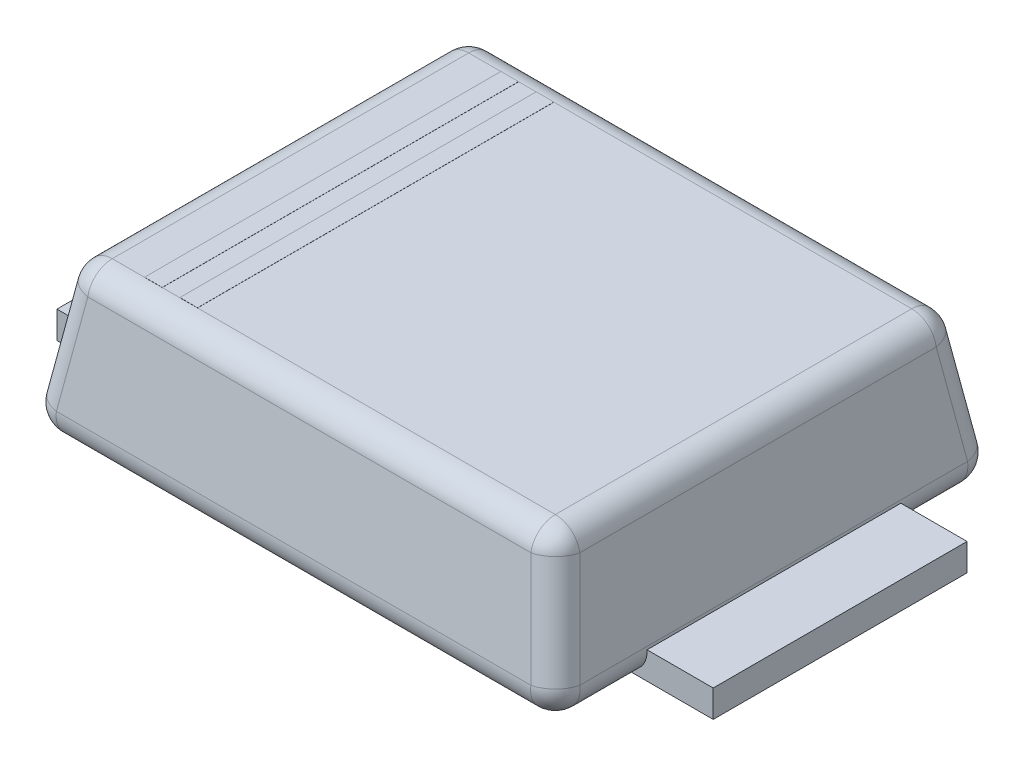
from build123d import *

# Parameters (mm, degrees)
SKETCH1_W           = 4.3
SKETCH1_H           = 3.6
BOSS_EXTRUDE1_DEPTH = 1.2
BOSS_EXTRUDE1_TAPER = 9
FILLET1_R           = 0.2
SKETCH3_W           = 1
SKETCH3_H           = 2.05
BOSS_EXTRUDE2_DEPTH = 0.22
SKETCH4_W           = 0.142609486
SKETCH4_H           = 2.87824507
SKETCH4_W_2         = 0.142609485
BOSS_EXTRUDE3_DEPTH = 0.001


with BuildPart() as part:
    # Sketch1 → Boss-Extrude1 (new body)
    with BuildSketch(Plane(origin=(0, 0, 0), x_dir=(1, 0, 0), z_dir=(0, 1, 0))):
        Rectangle(SKETCH1_W, SKETCH1_H)
    extrude(amount=BOSS_EXTRUDE1_DEPTH, taper=BOSS_EXTRUDE1_TAPER)

    # Fillet1
    fillet1_edges = [part.edges().sort_by_distance(p)[0] for p in [
        (-1.959938672, 1.2, 0),
        (0, 1.2, 1.609938672),
        (1.959938672, 1.2, 0),
        (0, 0, 1.8),
        (-2.15, 0, 0),
        (0, 0, -1.8),
        (2.15, 0, 0),
        (0, 1.2, -1.609938672),
        (2.054969336, 0.6, 1.704969336),
        (-2.054969336, 0.6, 1.704969336),
        (-2.054969336, 0.6, -1.704969336),
        (2.054969336, 0.6, -1.704969336),
    ]]
    fillet(fillet1_edges, radius=FILLET1_R)

    # Sketch3 → Boss-Extrude2 (add)
    with BuildSketch(Plane(origin=(0, -0.01, 0), x_dir=(-1, 0, 0), z_dir=(0, -1, 0))):
        with Locations((2.15, 0)):
            Rectangle(SKETCH3_W, SKETCH3_H)
        with Locations((-2.15, 0)):
            Rectangle(SKETCH3_W, SKETCH3_H)
    extrude(amount=-BOSS_EXTRUDE2_DEPTH)

    # Sketch4 → Boss-Extrude3 (add)
    with BuildSketch(Plane(origin=(0, 1.2, 0), x_dir=(1, 0, 0), z_dir=(0, 1, 0))):
        with Locations((-1.457146389, 0)):
            Rectangle(SKETCH4_W, SKETCH4_H)
        with Locations((-1.171927419, 0)):
            Rectangle(SKETCH4_W_2, SKETCH4_H)
    extrude(amount=BOSS_EXTRUDE3_DEPTH)


solid = part.part
